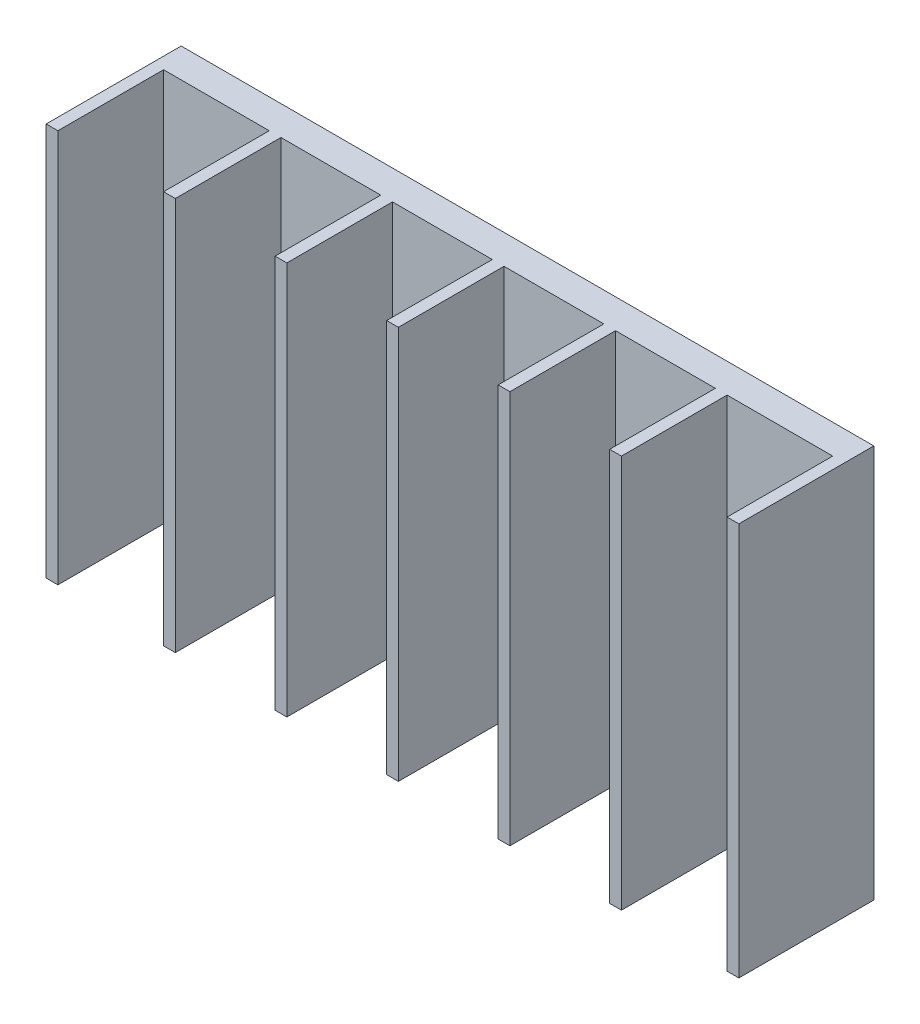
from build123d import *

# Parameters (mm, degrees)
SKETCH1_W           = 114
SKETCH1_H           = 67
BOSS_EXTRUDE1_DEPTH = 2.5
SKETCH2_W           = 2
SKETCH2_H           = 67
BOSS_EXTRUDE2_DEPTH = 18
LPATTERN1_COUNT     = 5
LPATTERN1_PITCH     = 19
SKETCH3_W           = 23
SKETCH3_H           = 67
BOSS_EXTRUDE3_DEPTH = 2


with BuildPart() as part:
    # Sketch1 → Boss-Extrude1 (new body, symmetric)
    with BuildSketch(Plane.XY):
        Rectangle(SKETCH1_W, SKETCH1_H)
    extrude(amount=BOSS_EXTRUDE1_DEPTH, both=True)

    # Sketch2 → Boss-Extrude2 (add)
    with BuildSketch(Plane.XY.offset(2.5)):
        with Locations((-38, 0)):
            Rectangle(SKETCH2_W, SKETCH2_H)
    boss_extrude2 = extrude(amount=BOSS_EXTRUDE2_DEPTH)

    # LPattern1: Boss-Extrude2 ×5
    with Locations(*[(i * LPATTERN1_PITCH, 0, 0) for i in range(1, LPATTERN1_COUNT)]):
        add(boss_extrude2)

    # Sketch3 → Boss-Extrude3 (add)
    with BuildSketch(Plane.ZY.offset(57)):
        with Locations((9, 0)):
            Rectangle(SKETCH3_W, SKETCH3_H)
    boss_extrude3 = extrude(amount=BOSS_EXTRUDE3_DEPTH)

    # Mirror1: Boss-Extrude3 across plane
    add(boss_extrude3.mirror(Plane(origin=(0, 0, 0), x_dir=(0, 0, 1), z_dir=(1, 0, 0))))


solid = part.part
